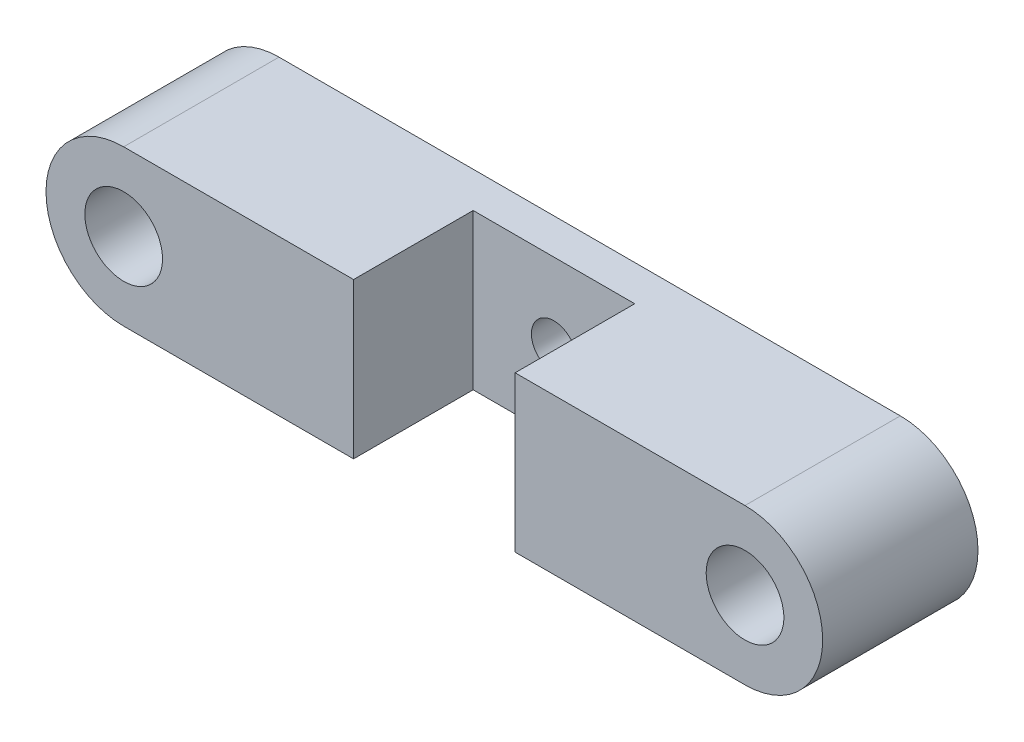
from build123d import *

# Parameters (mm, degrees)
SKETCH1_R           = 6.35
BOSS_EXTRUDE1_DEPTH = 25.4
SKETCH2_W           = 26.416
SKETCH2_H           = 39.116
CUT_EXTRUDE1_DEPTH  = 26.4
SKETCH3_R           = 3.683
CUT_EXTRUDE2_DEPTH  = 6.842


with BuildPart() as part:
    # Sketch1 → Boss-Extrude1 (new body)
    with BuildSketch(Plane.XY):
        with BuildLine():
            Line((-50.8, 12.7), (50.8, 12.7))
            ThreePointArc((50.8, 12.7), (63.5, 0), (50.8, -12.7))
            Line((50.8, -12.7), (-50.8, -12.7))
            ThreePointArc((-50.8, -12.7), (-63.5, 0), (-50.8, 12.7))
        make_face()
        with Locations((-50.8, 0)):
            Circle(SKETCH1_R, mode=Mode.SUBTRACT)
        with Locations((50.8, 0)):
            Circle(SKETCH1_R, mode=Mode.SUBTRACT)
    extrude(amount=BOSS_EXTRUDE1_DEPTH)

    # Sketch2 → Cut-Extrude1 (cut, through all)
    with BuildSketch(Plane(origin=(0, 12.7, 0), x_dir=(1, 0, 0), z_dir=(0, 1, 0))):
        with Locations((0, -25.4)):
            Rectangle(SKETCH2_W, SKETCH2_H)
    extrude(amount=-CUT_EXTRUDE1_DEPTH, mode=Mode.SUBTRACT)

    # Sketch3 → Cut-Extrude2 (cut, through all)
    with BuildSketch(Plane.XY.offset(5.842)):
        Circle(SKETCH3_R)
    extrude(amount=-CUT_EXTRUDE2_DEPTH, mode=Mode.SUBTRACT)


solid = part.part
